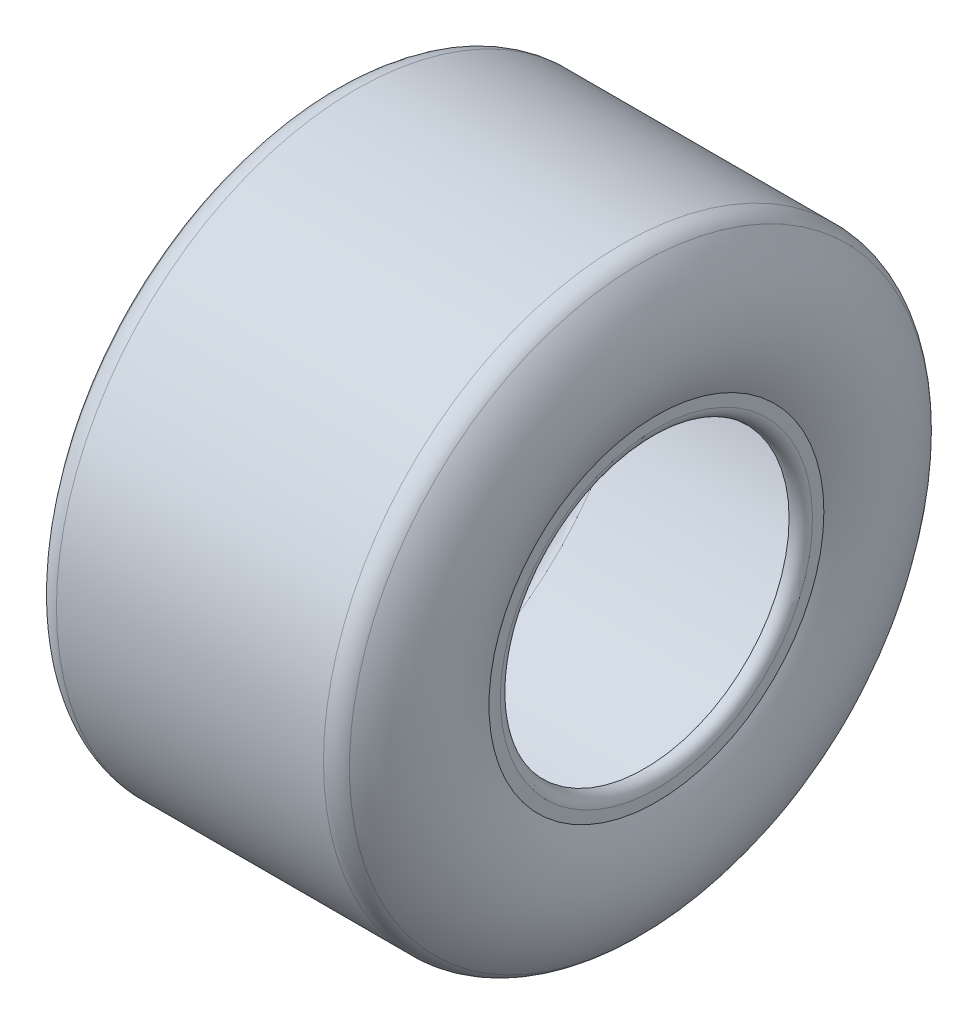
from build123d import *


with BuildPart() as part:
    # Sketch1 → Revolve1 (revolve)
    with BuildSketch(Plane.XY):
        with BuildLine():
            Line((-70, 70), (-70, 65.23))
            ThreePointArc((-70, 65.23), (-68.487899346, 61.809466094), (-65, 60.46))
            Line((-65, 60.46), (-65, 71.223033879))
            ThreePointArc((-65, 71.223033879), (-69.681555571, 95.622688733), (-59.560570448, 118.312461312))
            ThreePointArc((-59.560570448, 118.312461312), (-57.8692098, 119.558635024), (-55.815226664, 120))
            Line((-55.815226664, 120), (0, 120))
            Line((0, 120), (55.815226664, 120))
            ThreePointArc((55.815226664, 120), (57.8692098, 119.558635024), (59.560570448, 118.312461312))
            ThreePointArc((59.560570448, 118.312461312), (69.681555571, 95.622688733), (65, 71.223033879))
            Line((65, 71.223033879), (65, 60.46))
            ThreePointArc((65, 60.46), (68.487899346, 61.809466094), (70, 65.23))
            Line((70, 65.23), (70, 70))
            ThreePointArc((70, 70), (74.569757908, 96.839014783), (63.305914232, 121.624922623))
            ThreePointArc((63.305914232, 121.624922623), (59.923192935, 124.117270047), (55.815226664, 125))
            Line((55.815226664, 125), (0, 125))
            Line((0, 125), (-55.815226664, 125))
            ThreePointArc((-55.815226664, 125), (-59.923192935, 124.117270047), (-63.305914232, 121.624922623))
            ThreePointArc((-63.305914232, 121.624922623), (-74.569757908, 96.839014783), (-70, 70))
        make_face()
    revolve(axis=Axis((0, 0, 0), (-1, 0, 0)))


solid = part.part
